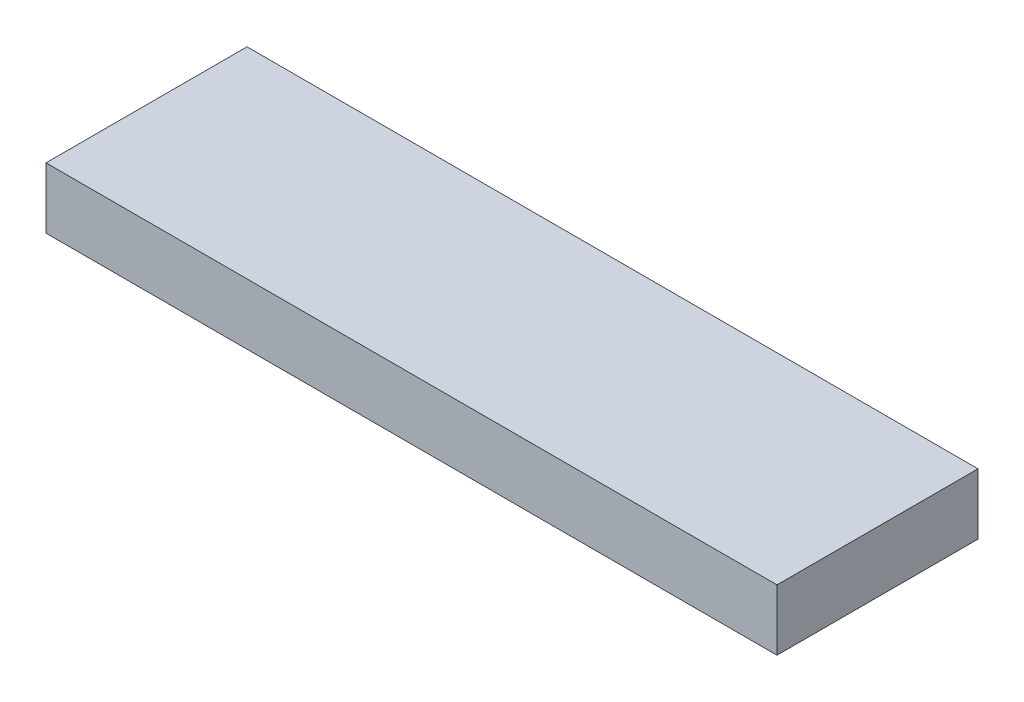
from build123d import *

# Parameters (mm, degrees)
SKETCH2_W           = 120
SKETCH2_H           = 33
BOSS_EXTRUDE1_DEPTH = 10


with BuildPart() as part:
    # Sketch2 → Boss-Extrude1 (new body)
    with BuildSketch(Plane(origin=(0, 0, 0), x_dir=(1, 0, 0), z_dir=(0, 1, 0))):
        with Locations((60, 16.5)):
            Rectangle(SKETCH2_W, SKETCH2_H)
    extrude(amount=BOSS_EXTRUDE1_DEPTH)


solid = part.part
